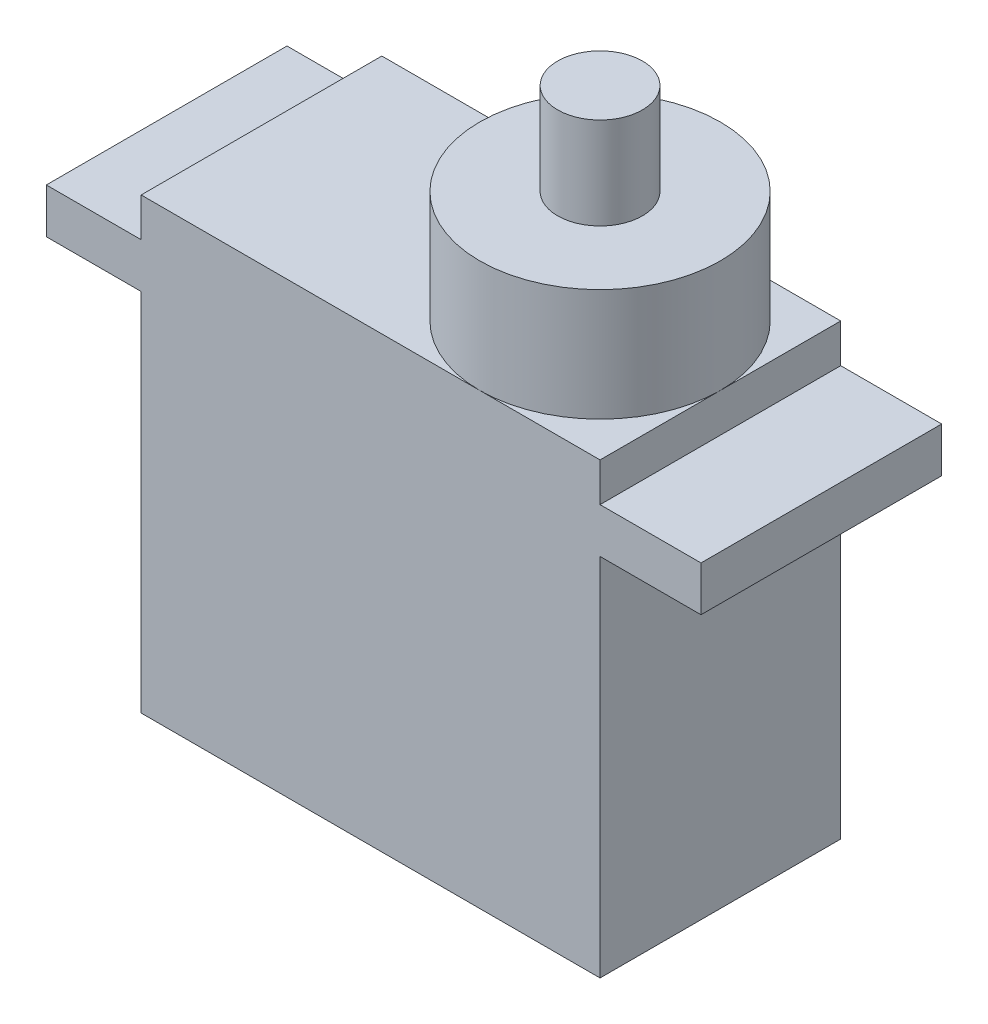
from build123d import *

# Parameters (mm, degrees)
SKETCH1_W           = 22.5
SKETCH1_H           = 11.8
BOSS_EXTRUDE1_DEPTH = 17.9
SKETCH2_W           = 22.5
SKETCH2_H           = 11.8
BOSS_EXTRUDE2_DEPTH = 4.1
SKETCH3_R           = 5.9
BOSS_EXTRUDE3_DEPTH = 5.5
SKETCH4_R           = 2.078257601
BOSS_EXTRUDE4_DEPTH = 4.5
SKETCH5_W           = 32.1
SKETCH5_H           = 11.8
BOSS_EXTRUDE5_DEPTH = 2.2


with BuildPart() as part:
    # Sketch1 → Boss-Extrude1 (new body)
    with BuildSketch(Plane(origin=(0, 0, 0), x_dir=(1, 0, 0), z_dir=(0, 1, 0))):
        with Locations((11.25, 5.9)):
            Rectangle(SKETCH1_W, SKETCH1_H)
    extrude(amount=BOSS_EXTRUDE1_DEPTH)

    # Sketch2 → Boss-Extrude2 (add)
    with BuildSketch(Plane(origin=(0, 17.9, 0), x_dir=(1, 0, 0), z_dir=(0, 1, 0))):
        with Locations((11.25, 5.9)):
            Rectangle(SKETCH2_W, SKETCH2_H)
    extrude(amount=BOSS_EXTRUDE2_DEPTH)

    # Sketch3 → Boss-Extrude3 (add)
    with BuildSketch(Plane(origin=(0, 22, 0), x_dir=(1, 0, 0), z_dir=(0, 1, 0))):
        with Locations((16.6, 5.9)):
            Circle(SKETCH3_R)
    extrude(amount=BOSS_EXTRUDE3_DEPTH)

    # Sketch4 → Boss-Extrude4 (add)
    with BuildSketch(Plane(origin=(0, 27.5, 0), x_dir=(1, 0, 0), z_dir=(0, 1, 0))):
        with Locations((16.6, 5.9)):
            Circle(SKETCH4_R)
    extrude(amount=BOSS_EXTRUDE4_DEPTH)

    # Sketch5 → Boss-Extrude5 (add)
    with BuildSketch(Plane(origin=(0, 17.9, 0), x_dir=(1, 0, 0), z_dir=(0, 1, 0))):
        with Locations((11.4, 5.9)):
            Rectangle(SKETCH5_W, SKETCH5_H)
    extrude(amount=BOSS_EXTRUDE5_DEPTH)


solid = part.part
